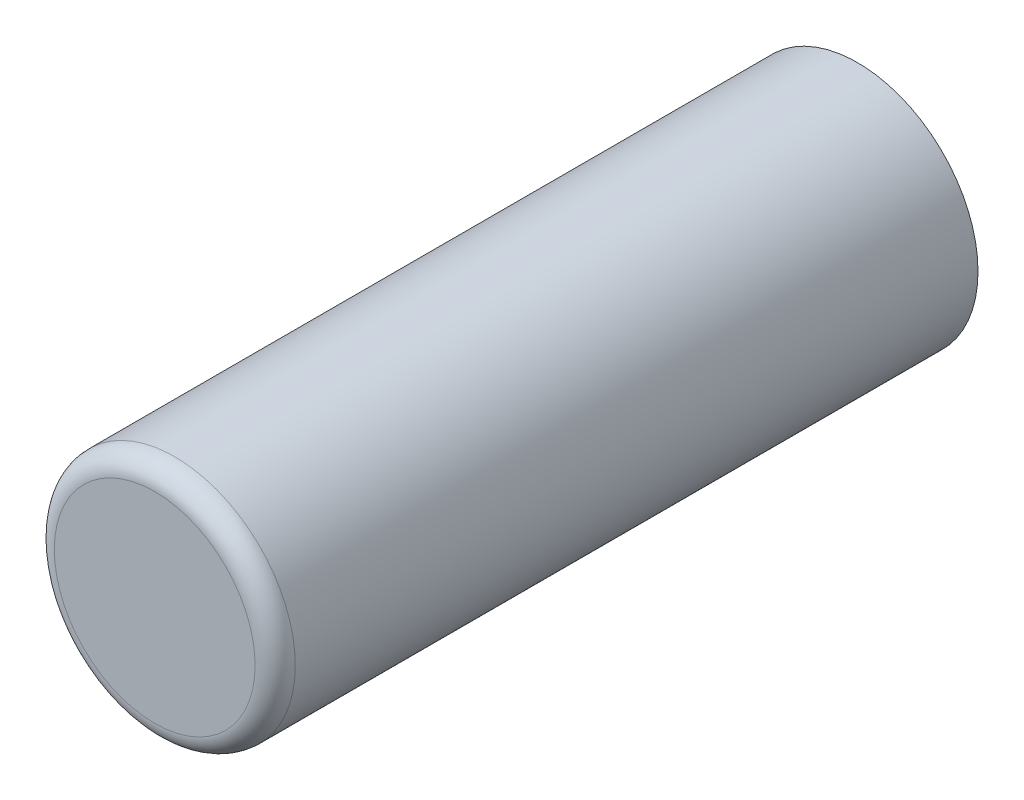
from build123d import *

# Parameters (mm, degrees)
SKETCH1_R           = 4.8
BOSS_EXTRUDE1_DEPTH = 14
FILLET1_R           = 0.8


with BuildPart() as part:
    # Sketch1 → Boss-Extrude1 (new body, symmetric)
    with BuildSketch(Plane.XY):
        Circle(SKETCH1_R)
    extrude(amount=BOSS_EXTRUDE1_DEPTH, both=True)

    # Fillet1
    fillet1_edges = [part.edges().sort_by_distance(p)[0] for p in [
        (-4.8, 0, 14),
    ]]
    fillet(fillet1_edges, radius=FILLET1_R)


solid = part.part
